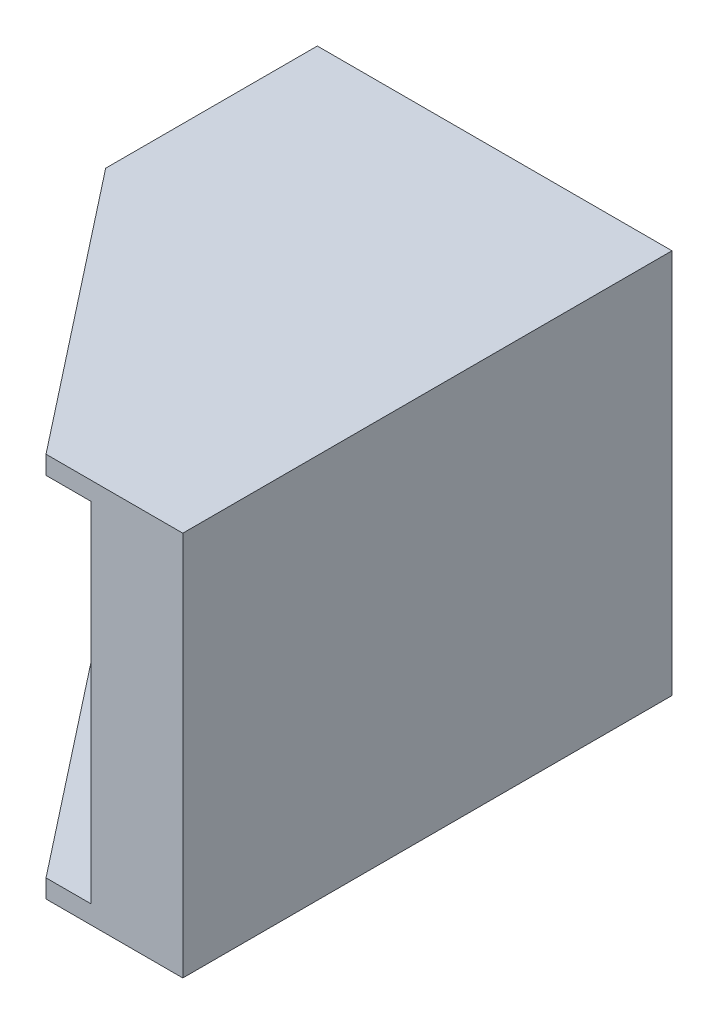
from build123d import *

# Parameters (mm, degrees)
SKETCH_1_W          = 58
SKETCH_1_H          = 63
EXTRUDE_1_DEPTH     = 60
SKETCH_3_W          = 43
SKETCH_3_H          = 57
CUT_EXTRUDE_1_DEPTH = 56
CUT_EXTRUDE_2_DEPTH = 64
SKETCH_5_W          = 58
SKETCH_5_H          = 63
EXTRUDE_2_DEPTH     = 20


with BuildPart() as part:
    # 草图1 → 凸台-拉伸1 (new body)
    with BuildSketch(Plane.XY):
        with Locations((-34.85212532, 1.584978346)):
            Rectangle(SKETCH_1_W, SKETCH_1_H)
    extrude(amount=EXTRUDE_1_DEPTH)

    # 草图3 → 切除-拉伸1 (cut)
    with BuildSketch(Plane.XY.offset(60)):
        with Locations((-42.35212532, 1.584978346)):
            Rectangle(SKETCH_3_W, SKETCH_3_H)
    extrude(amount=-CUT_EXTRUDE_1_DEPTH, mode=Mode.SUBTRACT)

    # 草图4 → 切除-拉伸2 (cut, through all)
    with BuildSketch(Plane.XZ.offset(29.915021654)):
        Polygon((-63.85212532, 60), (-63.85212532, 14.614911021), (-28.222040277, 60), align=None)
    extrude(amount=-CUT_EXTRUDE_2_DEPTH, mode=Mode.SUBTRACT)

    # 草图5 → 凸台-拉伸2 (add)
    with BuildSketch(Plane(origin=(0, 0, 0), x_dir=(-1, 0, 0), z_dir=(0, 0, -1))):
        with Locations((34.85212532, 1.584978346)):
            Rectangle(SKETCH_5_W, SKETCH_5_H)
    extrude(amount=EXTRUDE_2_DEPTH)


solid = part.part
